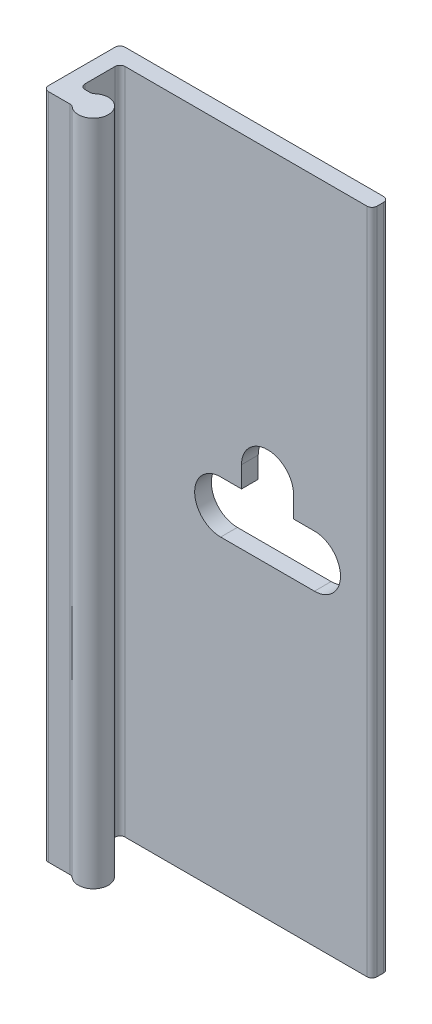
from build123d import *

# Parameters (mm, degrees)
BOSS_EXTRUDE1_DEPTH = 50.8
SKETCH4_W           = 5.715
SKETCH4_H           = 6.223
CUT_EXTRUDE2_DEPTH  = 51.8
FILLET1_R           = 0.381
CUT_EXTRUDE1_DEPTH  = 2.27


with BuildPart() as part:
    # Sketch2 → Boss-Extrude1 (new body)
    with BuildSketch(Plane(origin=(0, 0, 0), x_dir=(1, 0, 0), z_dir=(0, 1, 0))):
        with BuildLine():
            Line((-5.969, 0), (19.431, 0))
            ThreePointArc((19.431, 0), (19.700407684, -0.111592316), (19.812, -0.381))
            Line((19.812, -0.381), (19.812, -0.889))
            ThreePointArc((19.812, -0.889), (19.700407684, -1.158407684), (19.431, -1.27))
            Line((19.431, -1.27), (1.016, -1.27))
            ThreePointArc((1.016, -1.27), (0.746592316, -1.381592316), (0.635, -1.651))
            Line((0.635, -1.651), (0.635, -3.937))
            ThreePointArc((0.635, -3.937), (0.746592316, -4.206407684), (1.016, -4.318))
            Line((1.016, -4.318), (1.40496875, -4.318))
            ThreePointArc((1.40496875, -4.318), (1.539672592, -4.293392866), (1.656976563, -4.22275))
            ThreePointArc((1.656976563, -4.22275), (3.556, -5.08), (1.656976563, -5.93725))
            ThreePointArc((1.656976563, -5.93725), (1.539672592, -5.866607134), (1.40496875, -5.842))
            Line((1.40496875, -5.842), (-1.40496875, -5.842))
            ThreePointArc((-1.40496875, -5.842), (-1.539672592, -5.866607134), (-1.656976563, -5.93725))
            ThreePointArc((-1.656976563, -5.93725), (-3.556, -5.08), (-1.656976563, -4.22275))
            ThreePointArc((-1.656976563, -4.22275), (-1.539672592, -4.293392866), (-1.40496875, -4.318))
            Line((-1.40496875, -4.318), (-1.016, -4.318))
            ThreePointArc((-1.016, -4.318), (-0.746592316, -4.206407684), (-0.635, -3.937))
            Line((-0.635, -3.937), (-0.635, -1.651))
            ThreePointArc((-0.635, -1.651), (-0.746592316, -1.381592316), (-1.016, -1.27))
            Line((-1.016, -1.27), (-5.969, -1.27))
            ThreePointArc((-5.969, -1.27), (-6.238407684, -1.158407684), (-6.35, -0.889))
            Line((-6.35, -0.889), (-6.35, -0.381))
            ThreePointArc((-6.35, -0.381), (-6.238407684, -0.111592316), (-5.969, 0))
        make_face()
    extrude(amount=BOSS_EXTRUDE1_DEPTH)

    # Sketch4 → Cut-Extrude2 (cut, through all)
    with BuildSketch(Plane.XZ):
        with Locations((-3.4925, 3.1115)):
            Rectangle(SKETCH4_W, SKETCH4_H)
    extrude(amount=-CUT_EXTRUDE2_DEPTH, mode=Mode.SUBTRACT)

    # Fillet1
    fillet1_edges = [part.edges().sort_by_distance(p)[0] for p in [
        (-0.635, 25.4, 5.842),
        (-0.635, 25.4, 0),
    ]]
    fillet(fillet1_edges, radius=FILLET1_R)

    # Sketch3 → Cut-Extrude1 (cut, through all)
    with BuildSketch(Plane.XY.offset(1.27)):
        with BuildLine():
            Line((8.2931, 27.3812), (9.8806, 27.3812))
            Line((9.8806, 27.3812), (9.8806, 28.9814))
            ThreePointArc((9.8806, 28.9814), (11.8618, 30.9626), (13.843, 28.9814))
            Line((13.843, 28.9814), (13.843, 27.3812))
            Line((13.843, 27.3812), (15.4305, 27.3812))
            ThreePointArc((15.4305, 27.3812), (17.4117, 25.4), (15.4305, 23.4188))
            Line((15.4305, 23.4188), (8.2931, 23.4188))
            ThreePointArc((8.2931, 23.4188), (6.3119, 25.4), (8.2931, 27.3812))
        make_face()
    extrude(amount=-CUT_EXTRUDE1_DEPTH, mode=Mode.SUBTRACT)


solid = part.part
